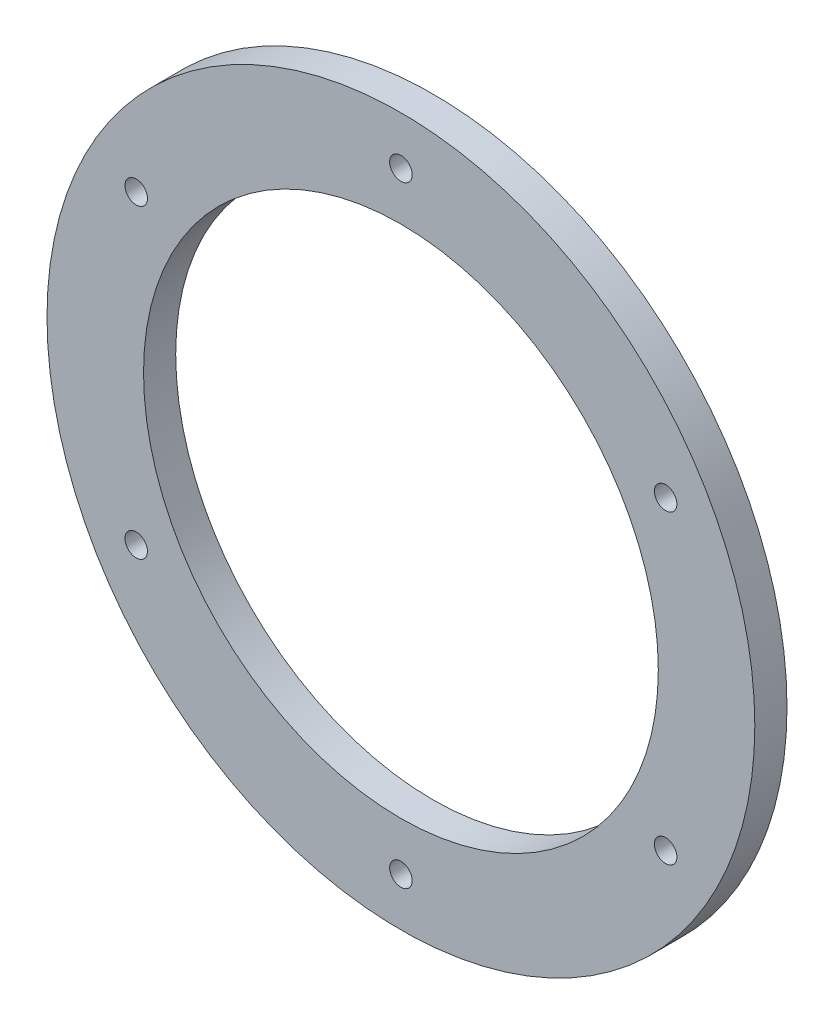
from build123d import *

# Parameters (mm, degrees)
ESQUISSE1_R        = 55
ESQUISSE1_R_2      = 40
ESQUISSE1_R_3      = 1.75
BOSS_EXTRU_1_DEPTH = 5


with BuildPart() as part:
    # Esquisse1 → Boss.-Extru.1 (new body)
    with BuildSketch(Plane.XY):
        Circle(ESQUISSE1_R)
        Circle(ESQUISSE1_R_2, mode=Mode.SUBTRACT)
        with Locations((0, 47.5)):
            Circle(ESQUISSE1_R_3, mode=Mode.SUBTRACT)
        with Locations((41.13620668, 23.75)):
            Circle(ESQUISSE1_R_3, mode=Mode.SUBTRACT)
        with Locations((41.13620668, -23.75)):
            Circle(ESQUISSE1_R_3, mode=Mode.SUBTRACT)
        with Locations((0, -47.5)):
            Circle(ESQUISSE1_R_3, mode=Mode.SUBTRACT)
        with Locations((-41.13620668, -23.75)):
            Circle(ESQUISSE1_R_3, mode=Mode.SUBTRACT)
        with Locations((-41.13620668, 23.75)):
            Circle(ESQUISSE1_R_3, mode=Mode.SUBTRACT)
    extrude(amount=BOSS_EXTRU_1_DEPTH)


solid = part.part
